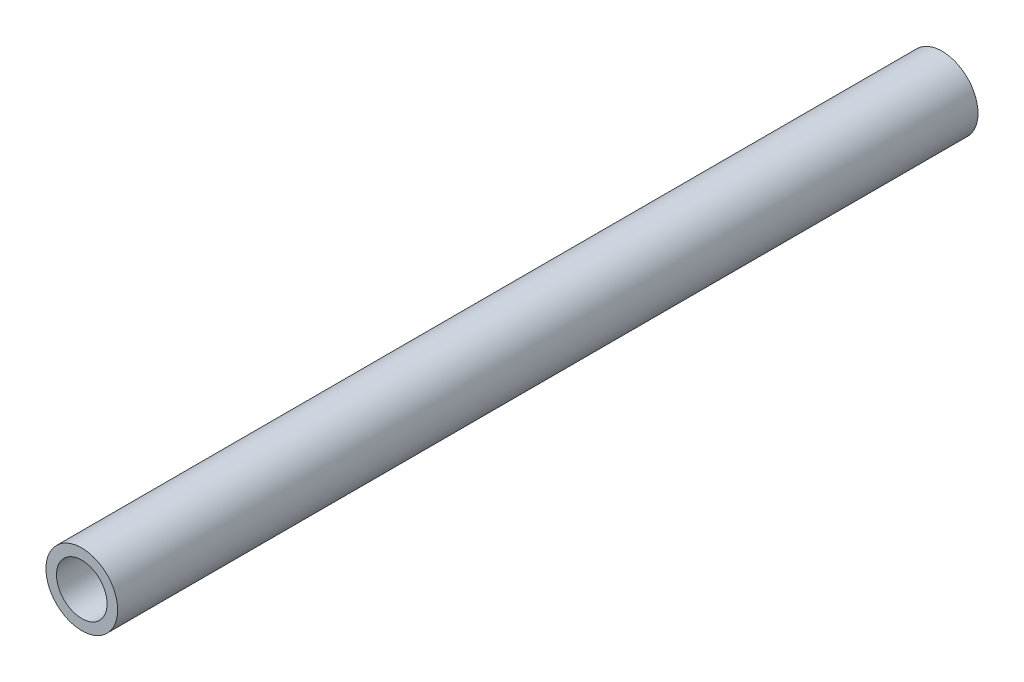
from build123d import *

# Parameters (mm, degrees)
SKETCH2_R           = 6.35
SKETCH2_R_2         = 4.4831
BOSS_EXTRUDE1_DEPTH = 152.4


with BuildPart() as part:
    # Sketch2 → Boss-Extrude1 (new body)
    with BuildSketch(Plane.XY):
        Circle(SKETCH2_R)
        Circle(SKETCH2_R_2, mode=Mode.SUBTRACT)
    extrude(amount=BOSS_EXTRUDE1_DEPTH)


solid = part.part
